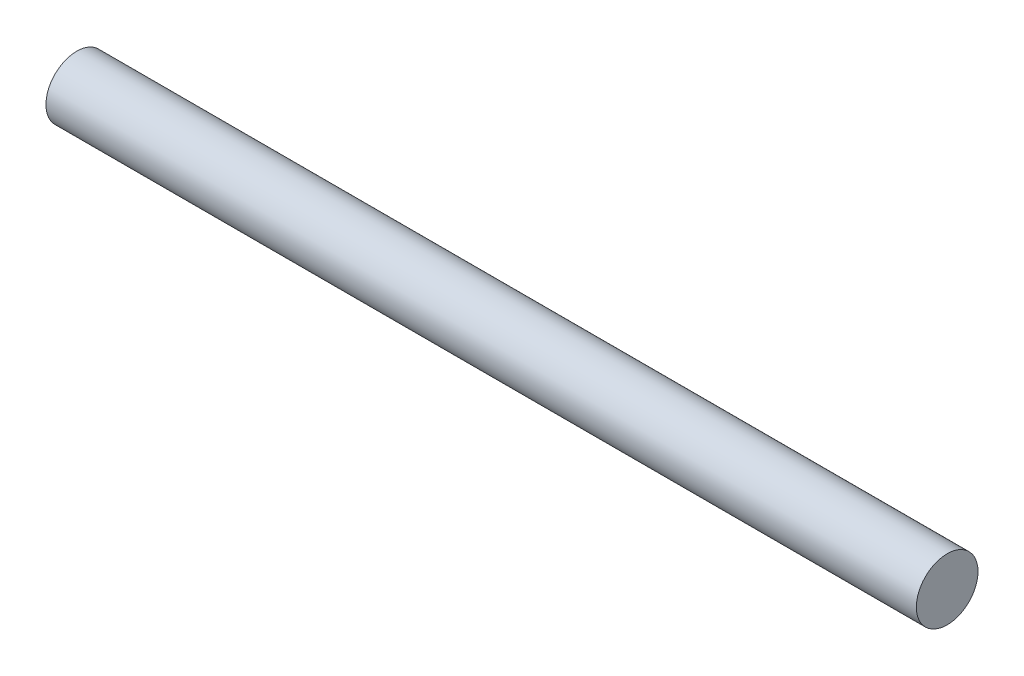
from build123d import *

# Parameters (mm, degrees)
SKETCH1_R           = 10.795
BOSS_EXTRUDE1_DEPTH = 152.4


with BuildPart() as part:
    # Sketch1 → Boss-Extrude1 (new body, symmetric)
    with BuildSketch(Plane(origin=(0, 0, 0), x_dir=(0, 0, -1), z_dir=(1, 0, 0))):
        Circle(SKETCH1_R)
    extrude(amount=BOSS_EXTRUDE1_DEPTH, both=True)


solid = part.part
